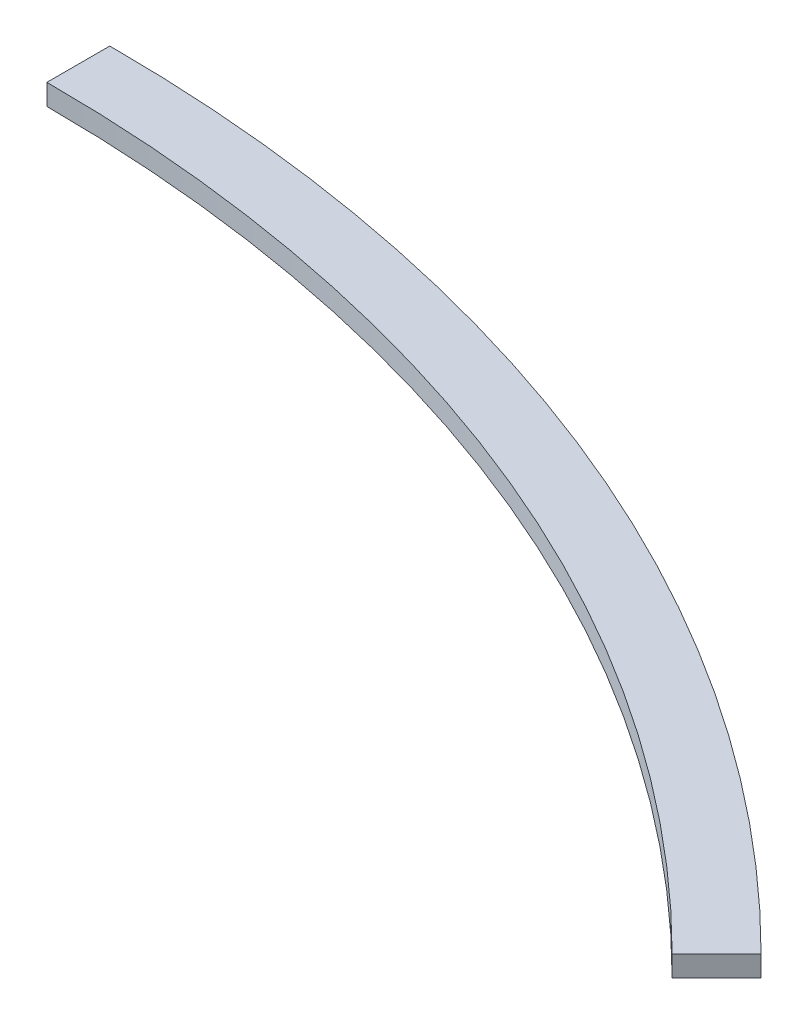
from build123d import *

# Parameters (mm, degrees)
BOSS_EXTRUDE1_DEPTH = 10


with BuildPart() as part:
    # Sketch1 → Boss-Extrude1 (new body)
    with BuildSketch(Plane(origin=(0, 0, 0), x_dir=(1, 0, 0), z_dir=(0, 1, 0))):
        with BuildLine():
            Line((0, 720), (0, 750))
            ThreePointArc((0, 750), (287.012574274, 692.909649383), (530.33008589, 530.33008589))
            Line((530.33008589, 530.33008589), (509.116882454, 509.116882454))
            ThreePointArc((509.116882454, 509.116882454), (275.532071303, 665.193263408), (0, 720))
        make_face()
    extrude(amount=BOSS_EXTRUDE1_DEPTH)


solid = part.part
